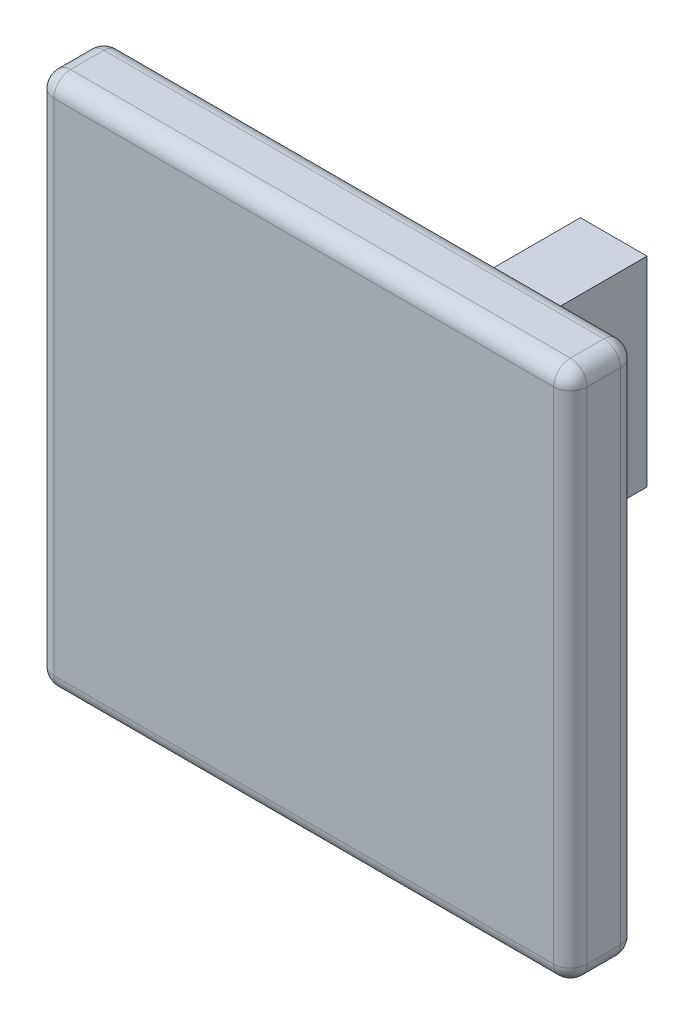
from build123d import *

# Parameters (mm, degrees)
SKETCH1_W           = 2
SKETCH1_H           = 7.3
BOSS_EXTRUDE1_DEPTH = 6
SKETCH3_W           = 16
SKETCH3_H           = 16
BOSS_EXTRUDE3_DEPTH = 2
FILLET2_R           = 0.5


with BuildPart() as part:
    # Sketch1 → Boss-Extrude1 (new body)
    with BuildSketch(Plane(origin=(0, 0, 0), x_dir=(1, 0, 0), z_dir=(0, 1, 0))):
        with Locations((1, 3.65)):
            Rectangle(SKETCH1_W, SKETCH1_H)
    extrude(amount=BOSS_EXTRUDE1_DEPTH)

    # Sketch3 → Boss-Extrude3 (add)
    with BuildSketch(Plane.XY):
        with Locations((1, 3)):
            Rectangle(SKETCH3_W, SKETCH3_H)
    extrude(amount=BOSS_EXTRUDE3_DEPTH)

    # Fillet2
    fillet2_edges = [part.edges().sort_by_distance(p)[0] for p in [
        (-7, 3, 0),
        (-7, 11, 1),
        (1, -5, 0),
        (-7, -5, 1),
        (9, 3, 0),
        (9, -5, 1),
        (1, 11, 0),
        (9, 11, 1),
        (-7, 3, 2),
        (1, -5, 2),
        (9, 3, 2),
        (1, 11, 2),
    ]]
    fillet(fillet2_edges, radius=FILLET2_R)


solid = part.part
